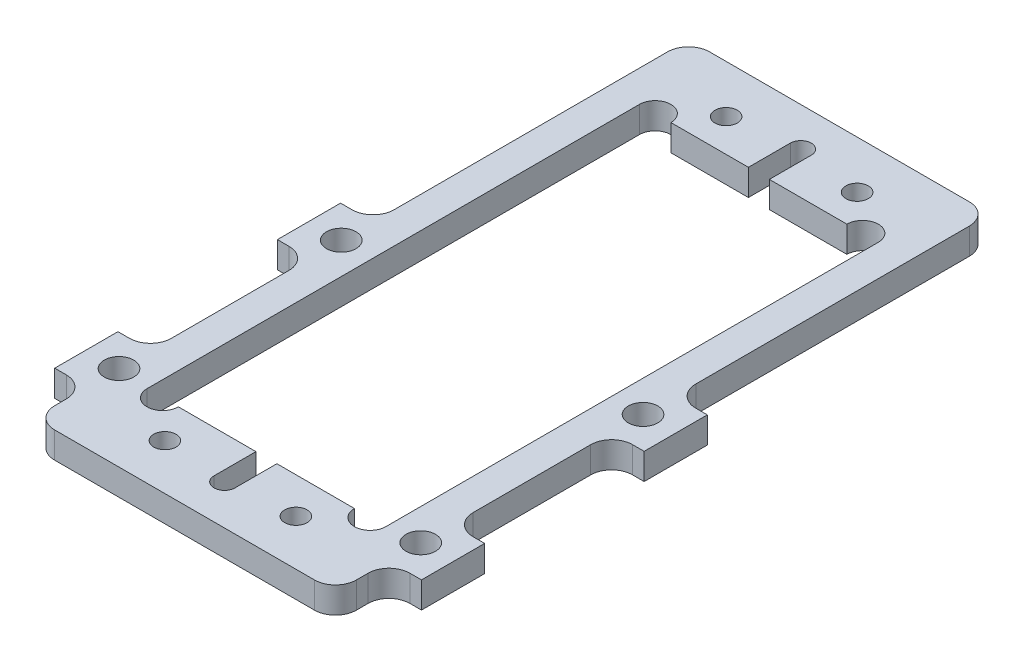
from build123d import *

# Parameters (mm, degrees)
SKETCH1_W                           = 28.956
SKETCH1_H                           = 59.69
BOSS_EXTRUDE1_DEPTH                 = 3.175
F_6_32_TAPPED_HOLE1_D               = 2.7051
F_6_32_TAPPED_HOLE1_DEPTH           = 3.175
F_9_64_0_14063_DIAMETER_HOLE1_D     = 3.572002
F_9_64_0_14063_DIAMETER_HOLE1_DEPTH = 3.175
FILLET1_R                           = 2.54
CUT_EXTRUDE1_REACH                  = 5.175
CUT_EXTRUDE2_REACH                  = 5.175


with BuildPart() as part:
    # Sketch1 → Boss-Extrude1 (new body)
    with BuildSketch(Plane(origin=(0, 0, 0), x_dir=(1, 0, 0), z_dir=(0, 1, 0))):
        Polygon((18.288, -23.8125), (18.288, -17.3228), (22.225, -17.3228), (22.225, -9.6647), (18.288, -9.6647), (18.288, 9.6647), (22.225, 9.6647), (22.225, 17.3228), (18.288, 17.3228), (18.288, 55.5625), (-18.288, 55.5625), (-18.288, 17.3228), (-22.225, 17.3228), (-22.225, 9.6647), (-18.288, 9.6647), (-18.288, -9.6647), (-22.225, -9.6647), (-22.225, -17.3228), (-18.288, -17.3228), (-18.288, -23.8125), align=None)
        with Locations((0, 15.954375)):
            Rectangle(SKETCH1_W, SKETCH1_H, mode=Mode.SUBTRACT)
    extrude(amount=BOSS_EXTRUDE1_DEPTH)

    # #6-32 Tapped Hole1
    with Locations(Plane.XZ):
        with Locations((-7.9375, 18.25625), (7.9375, 18.25625), (7.9375, -49.76495), (-7.9375, -49.76495)):
            Hole(F_6_32_TAPPED_HOLE1_D / 2, depth=F_6_32_TAPPED_HOLE1_DEPTH)

    # 9/64 (0.14063) Diameter Hole1
    with Locations(Plane.XZ):
        with Locations((18.288, -13.470384182), (18.288, 13.470384182), (-18.288, -13.470384182), (-18.288, 13.470384182)):
            Hole(F_9_64_0_14063_DIAMETER_HOLE1_D / 2, depth=F_9_64_0_14063_DIAMETER_HOLE1_DEPTH)

    # Fillet1
    fillet1_edges = [part.edges().sort_by_distance(p)[0] for p in [
        (18.288, 1.5875, 23.8125),
        (-18.288, 1.5875, 23.8125),
        (-18.288, 1.5875, 17.3228),
        (-18.288, 1.5875, 9.6647),
        (-18.288, 1.5875, -9.6647),
        (-18.288, 1.5875, -17.3228),
        (-18.288, 1.5875, -55.5625),
        (18.288, 1.5875, -55.5625),
        (18.288, 1.5875, -17.3228),
        (18.288, 1.5875, -9.6647),
        (18.288, 1.5875, 9.6647),
        (18.288, 1.5875, 17.3228),
    ]]
    fillet(fillet1_edges, radius=FILLET1_R)

    # Sketch7 → Cut-Extrude1 (cut, up to next)
    with BuildSketch(Plane(origin=(0, 3.175, 0), x_dir=(1, 0, 0), z_dir=(0, 1, 0)), mode=Mode.PRIVATE) as cut_extrude1_sk1:
        with BuildLine():
            Line((1.27, -13.890625), (1.27, -18.970625))
            ThreePointArc((1.27, -18.970625), (0, -20.240625), (-1.27, -18.970625))
            Line((-1.27, -18.970625), (-1.27, -13.890625))
            ThreePointArc((-1.27, -13.890625), (0, -12.620625), (1.27, -13.890625))
        make_face()
    cut_extrude1_tool1 = extrude(cut_extrude1_sk1.sketch, amount=-CUT_EXTRUDE1_REACH, mode=Mode.PRIVATE) & part.part
    add(cut_extrude1_tool1.solids().sort_by_distance((0, 3.175, 16.430625))[0], mode=Mode.SUBTRACT)
    # Sketch7 → Cut-Extrude1 (cut, up to next)
    with BuildSketch(Plane(origin=(0, 3.175, 0), x_dir=(1, 0, 0), z_dir=(0, 1, 0)), mode=Mode.PRIVATE) as cut_extrude1_sk2:
        with BuildLine():
            Line((-1.27, 45.799375), (-1.27, 50.879375))
            ThreePointArc((-1.27, 50.879375), (0, 52.149375), (1.27, 50.879375))
            Line((1.27, 50.879375), (1.27, 45.799375))
            ThreePointArc((1.27, 45.799375), (0, 44.529375), (-1.27, 45.799375))
        make_face()
    cut_extrude1_tool2 = extrude(cut_extrude1_sk2.sketch, amount=-CUT_EXTRUDE1_REACH, mode=Mode.PRIVATE) & part.part
    add(cut_extrude1_tool2.solids().sort_by_distance((0, 3.175, -48.339375))[0], mode=Mode.SUBTRACT)

    # Sketch8 → Cut-Extrude2 (cut, up to next)
    with BuildSketch(Plane(origin=(0, 3.175, 0), x_dir=(1, 0, 0), z_dir=(0, 1, 0)), mode=Mode.PRIVATE) as cut_extrude2_sk1:
        with BuildLine():
            Line((14.478, 45.799375), (10.668, 45.799375))
            ThreePointArc((10.668, 45.799375), (12.573, 47.704375), (14.478, 45.799375))
        make_face()
    cut_extrude2_tool1 = extrude(cut_extrude2_sk1.sketch, amount=-CUT_EXTRUDE2_REACH, mode=Mode.PRIVATE) & part.part
    add(cut_extrude2_tool1.solids().sort_by_distance((12.573, 3.175, -46.607882))[0], mode=Mode.SUBTRACT)
    # Sketch8 → Cut-Extrude2 (cut, up to next)
    with BuildSketch(Plane(origin=(0, 3.175, 0), x_dir=(1, 0, 0), z_dir=(0, 1, 0)), mode=Mode.PRIVATE) as cut_extrude2_sk2:
        with BuildLine():
            Line((-14.478, 45.799375), (-10.668, 45.799375))
            ThreePointArc((-10.668, 45.799375), (-12.573, 47.704375), (-14.478, 45.799375))
        make_face()
    cut_extrude2_tool2 = extrude(cut_extrude2_sk2.sketch, amount=-CUT_EXTRUDE2_REACH, mode=Mode.PRIVATE) & part.part
    add(cut_extrude2_tool2.solids().sort_by_distance((-12.573, 3.175, -46.607882))[0], mode=Mode.SUBTRACT)
    # Sketch8 → Cut-Extrude2 (cut, up to next)
    with BuildSketch(Plane(origin=(0, 3.175, 0), x_dir=(1, 0, 0), z_dir=(0, 1, 0)), mode=Mode.PRIVATE) as cut_extrude2_sk3:
        with BuildLine():
            Line((-14.478, -13.890625), (-10.668, -13.890625))
            ThreePointArc((-10.668, -13.890625), (-12.573, -15.795625), (-14.478, -13.890625))
        make_face()
    cut_extrude2_tool3 = extrude(cut_extrude2_sk3.sketch, amount=-CUT_EXTRUDE2_REACH, mode=Mode.PRIVATE) & part.part
    add(cut_extrude2_tool3.solids().sort_by_distance((-12.573, 3.175, 14.699132))[0], mode=Mode.SUBTRACT)
    # Sketch8 → Cut-Extrude2 (cut, up to next)
    with BuildSketch(Plane(origin=(0, 3.175, 0), x_dir=(1, 0, 0), z_dir=(0, 1, 0)), mode=Mode.PRIVATE) as cut_extrude2_sk4:
        with BuildLine():
            Line((10.668, -13.890625), (14.478, -13.890625))
            ThreePointArc((14.478, -13.890625), (12.573, -15.795625), (10.668, -13.890625))
        make_face()
    cut_extrude2_tool4 = extrude(cut_extrude2_sk4.sketch, amount=-CUT_EXTRUDE2_REACH, mode=Mode.PRIVATE) & part.part
    add(cut_extrude2_tool4.solids().sort_by_distance((12.573, 3.175, 14.699132))[0], mode=Mode.SUBTRACT)


solid = part.part
